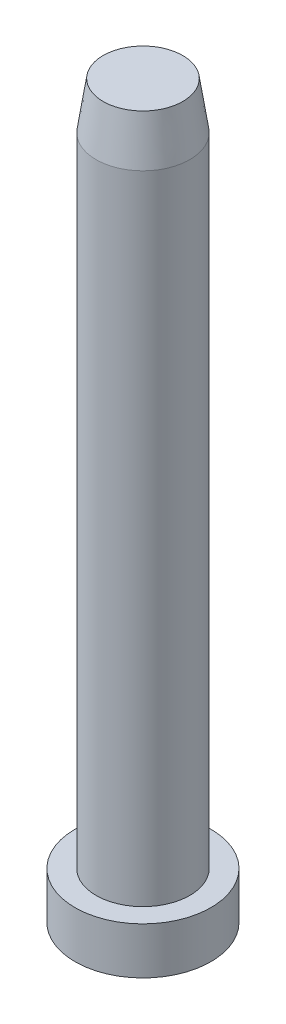
from build123d import *


with BuildPart() as part:
    # Sketch5 → Revolve1 (revolve)
    with BuildSketch(Plane.XY):
        Polygon((0, 0), (7.25, 0), (7.25, 5), (5, 5), (5, 73), (4.25, 78), (0, 78), align=None)
    revolve(axis=Axis((0, 78, 0), (0, -1, 0)))


solid = part.part
